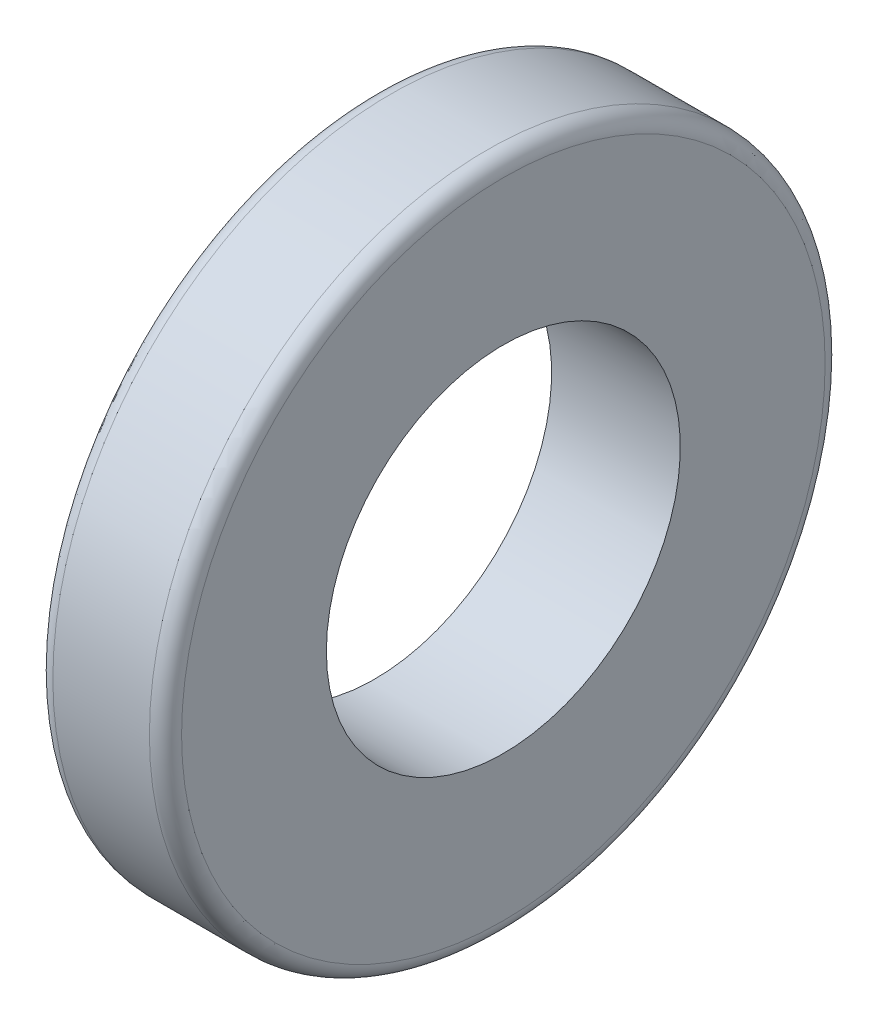
from build123d import *

# Parameters (mm, degrees)
SKETCH1_W = 4
SKETCH1_H = 5
FILLET1_R = 0.5


with BuildPart() as part:
    # Sketch1 → Revolve1 (revolve)
    with BuildSketch(Plane.XY):
        with Locations((3, 8)):
            Rectangle(SKETCH1_W, SKETCH1_H)
    revolve(axis=Axis((0, 0, 0), (1, 0, 0)))

    # Fillet1
    fillet1_edges = [part.edges().sort_by_distance(p)[0] for p in [
        (5, -10.5, 0),
        (1, -10.5, 0),
    ]]
    fillet(fillet1_edges, radius=FILLET1_R)


solid = part.part
